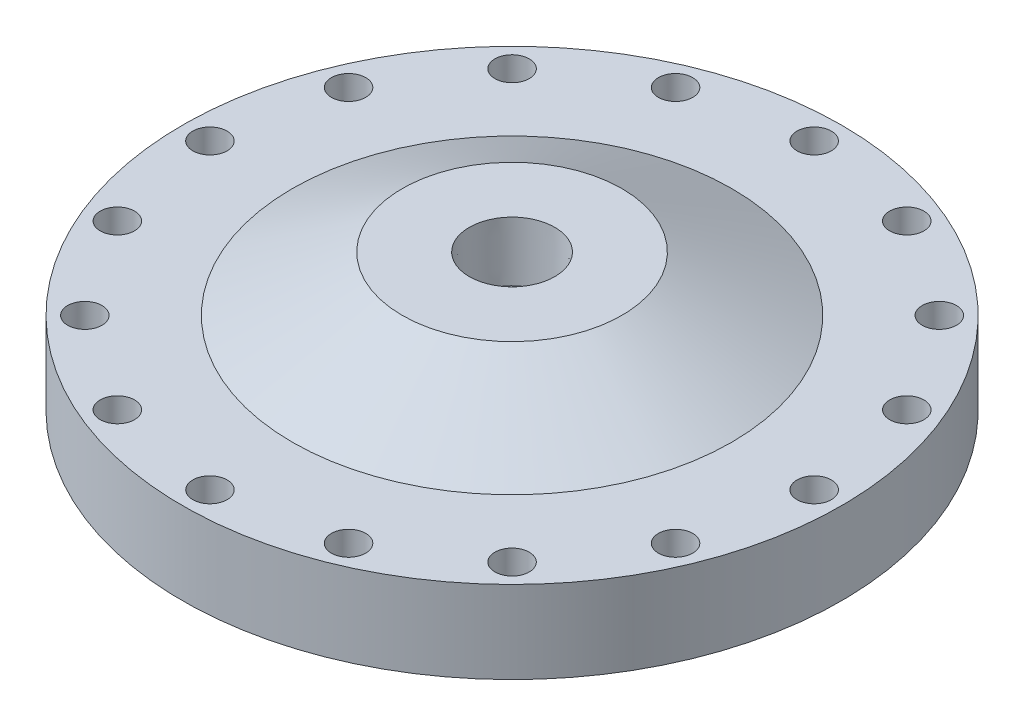
from build123d import *

# Parameters (mm, degrees)
CIRPATTERN1_COUNT = 16


with BuildPart() as part:
    # Sketch1 → Revolve1 (revolve)
    with BuildSketch(Plane.XY):
        Polygon((-76.2, -12.7), (-76.2, -31.75), (-42.8625, -31.75), (-15.875, -19.05), (0, -19.05), (0, 0), (-25.4, 0), (-50.8, -12.7), align=None)
    revolve(axis=Axis((0, -19.05, 0), (0, 1, 0)))

    # Sketch5 → 5_16 _0.3125_ Diameter Hole1 (revolve, cut)
    with BuildSketch(Plane(origin=(-69.85, -12.7, 0), x_dir=(0, 0, 1), z_dir=(1, 0, 0))):
        Polygon((0, 0), (0, 40.484665582), (3.96875, 38.1), (3.96875, 0), align=None)
    f_5_16_0_3125_diameter_hole1 = revolve(axis=Axis((-69.85, -6.35, 0), (0, -1, 0)), mode=Mode.SUBTRACT)

    # CirPattern1: 5_16 _0.3125_ Diameter Hole1 ×16 about axis
    cirpattern1_axis = Axis((0, 0, 0), (0, 1, 0))
    for i in range(1, CIRPATTERN1_COUNT):
        add(f_5_16_0_3125_diameter_hole1.rotate(cirpattern1_axis, i * 360 / CIRPATTERN1_COUNT), mode=Mode.SUBTRACT)

    # Sketch8 → 1_2 NPT Tapped Hole1 (revolve, cut)
    with BuildSketch(Plane(origin=(0, 0, 0), x_dir=(0, 0, 1), z_dir=(1, 0, 0))):
        Polygon((0, 0), (0, 19.05), (8.9281, 19.05), (8.9281, 13.462), (9.479726792, 13.462), (9.8827971, 0), align=None)
    revolve(axis=Axis((0, 6.35, 0), (0, -1, 0)), mode=Mode.SUBTRACT)


solid = part.part
